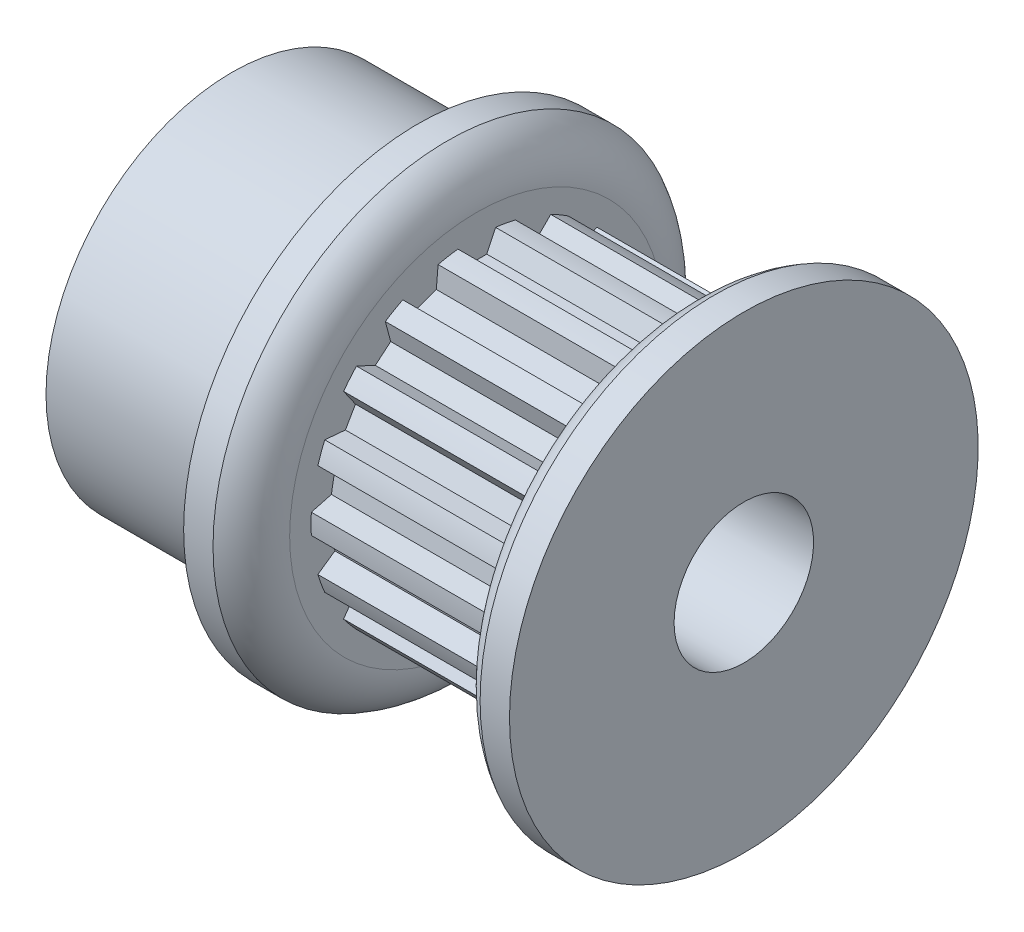
from build123d import *

# Parameters (mm, degrees)
SKETCH4_R          = 5.8166
SKETCH4_R_2        = 5.65785
CUT_EXTRUDE2_DEPTH = 7.112
CUT_EXTRUDE1_DEPTH = 7.112
CIRPATTERN1_COUNT  = 18


with BuildPart() as part:
    # Sketch1 → Revolve1 (revolve)
    with BuildSketch(Plane.XY, mode=Mode.PRIVATE) as revolve1_sk:
        with BuildLine():
            Line((-8.7376, 2.38125), (8.7376, 2.38125))
            Line((8.7376, 2.38125), (8.7376, 8.001))
            Line((8.7376, 8.001), (7.7343, 8.001))
            ThreePointArc((7.7343, 8.001), (7.002290733, 7.337844347), (6.731, 6.3881))
            Line((6.731, 6.3881), (6.731, 5.8166))
            Line((6.731, 5.8166), (-0.381, 5.8166))
            Line((-0.381, 5.8166), (-0.381, 6.3881))
            ThreePointArc((-0.381, 6.3881), (-0.652290733, 7.337844347), (-1.3843, 8.001))
            Line((-1.3843, 8.001), (-2.3876, 8.001))
            Line((-2.3876, 8.001), (-2.3876, 6.35))
            Line((-2.3876, 6.35), (-8.7376, 6.35))
            Line((-8.7376, 6.35), (-8.7376, 2.38125))
        make_face()
    revolve(revolve1_sk.sketch.rotate(Axis((-8.7376, 0, 0), (1, 0, 0)), 90), axis=Axis((-8.7376, 0, 0), (1, 0, 0)))

    # Sketch4 → Cut-Extrude2 (cut)
    with BuildSketch(Plane(origin=(-0.381, 0, 0), x_dir=(0, 0, -1), z_dir=(1, 0, 0))):
        Circle(SKETCH4_R)
        Circle(SKETCH4_R_2, mode=Mode.SUBTRACT)
    extrude(amount=CUT_EXTRUDE2_DEPTH, mode=Mode.SUBTRACT)

    # Sketch3 → Cut-Extrude1 (cut)
    with BuildSketch(Plane(origin=(-0.381, 0, 0), x_dir=(0, 0, -1), z_dir=(1, 0, 0))):
        with BuildLine():
            Line((-0.64235315, 5.621267566), (-0.342998874, 4.97930025))
            Line((-0.342998874, 4.97930025), (0.342998874, 4.97930025))
            Line((0.342998874, 4.97930025), (0.64235315, 5.621267566))
            ThreePointArc((0.64235315, 5.621267566), (0, 5.65785), (-0.64235315, 5.621267566))
        make_face()
    cut_extrude1 = extrude(amount=CUT_EXTRUDE1_DEPTH, mode=Mode.SUBTRACT)

    # CirPattern1: Cut-Extrude1 ×18 about axis
    cirpattern1_axis = Axis((0, 0, 0), (1, 0, 0))
    for i in range(1, CIRPATTERN1_COUNT):
        add(cut_extrude1.rotate(cirpattern1_axis, i * 360 / CIRPATTERN1_COUNT), mode=Mode.SUBTRACT)


solid = part.part
